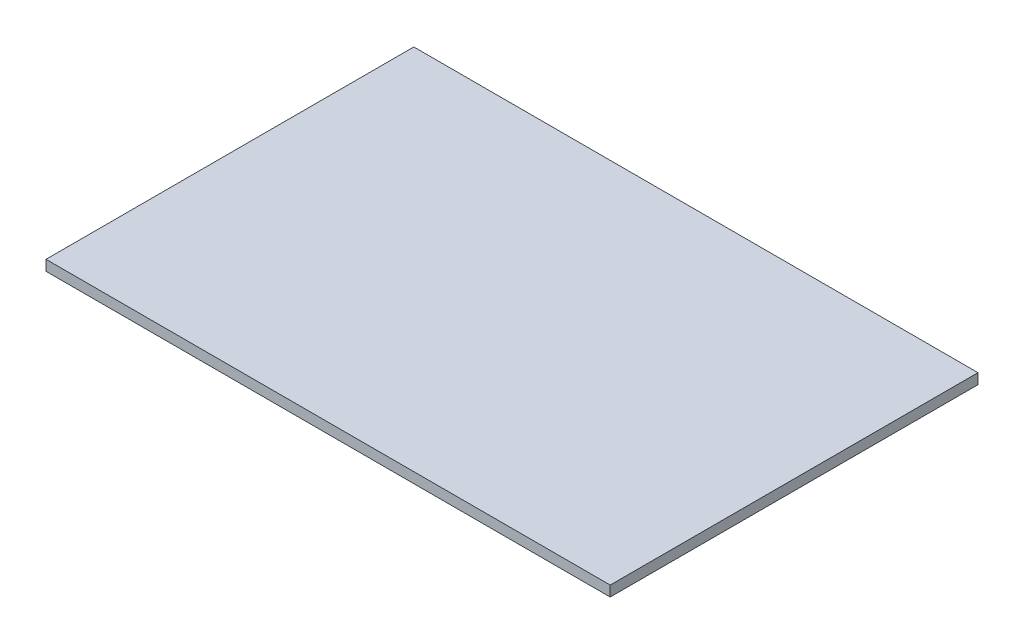
from build123d import *

# Parameters (mm, degrees)
CROQUIS1_W              = 81.3
CROQUIS1_H              = 53
SALIENTE_EXTRUIR1_DEPTH = 1.5


with BuildPart() as part:
    # Croquis1 → Saliente-Extruir1 (new body)
    with BuildSketch(Plane(origin=(0, 0, 0), x_dir=(1, 0, 0), z_dir=(0, 1, 0))):
        Rectangle(CROQUIS1_W, CROQUIS1_H)
    extrude(amount=SALIENTE_EXTRUIR1_DEPTH)


solid = part.part
